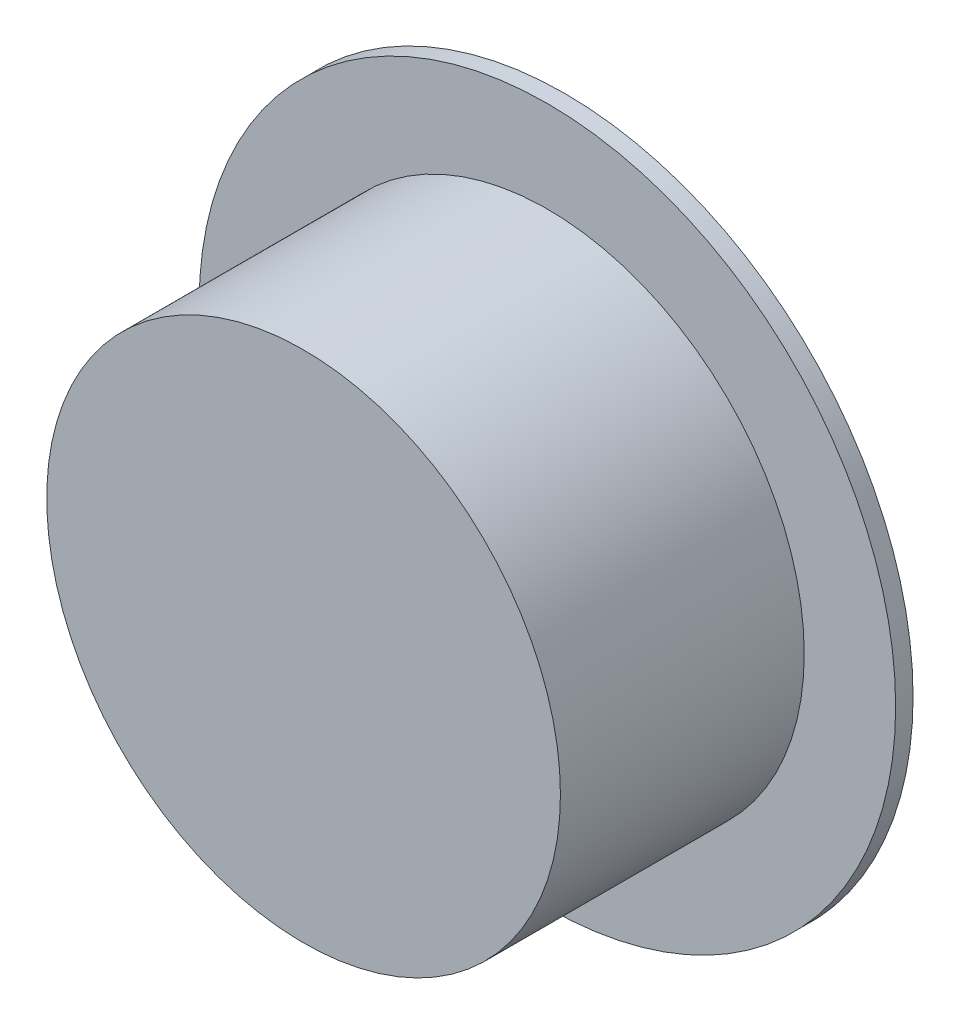
from build123d import *

# Parameters (mm, degrees)
SKETCH2_R           = 14.75
BOSS_EXTRUDE1_DEPTH = 7.5
BOSS_EXTRUDE2_START = -7.5
SKETCH3_R           = 20
BOSS_EXTRUDE2_DEPTH = 1
SKETCH4_R           = 12.5
CUT_EXTRUDE1_DEPTH  = 10


with BuildPart() as part:
    # Sketch2 → Boss-Extrude1 (new body, symmetric)
    with BuildSketch(Plane.XY):
        Circle(SKETCH2_R)
    extrude(amount=BOSS_EXTRUDE1_DEPTH, both=True)

    # Sketch3 → Boss-Extrude2 (add)
    with BuildSketch(Plane.XY.offset(BOSS_EXTRUDE2_START)):
        Circle(SKETCH3_R)
    extrude(amount=BOSS_EXTRUDE2_DEPTH)

    # Sketch4 → Cut-Extrude1 (cut)
    with BuildSketch(Plane(origin=(0, 0, -7.5), x_dir=(-1, 0, 0), z_dir=(0, 0, -1))):
        Circle(SKETCH4_R)
    extrude(amount=-CUT_EXTRUDE1_DEPTH, mode=Mode.SUBTRACT)


solid = part.part
